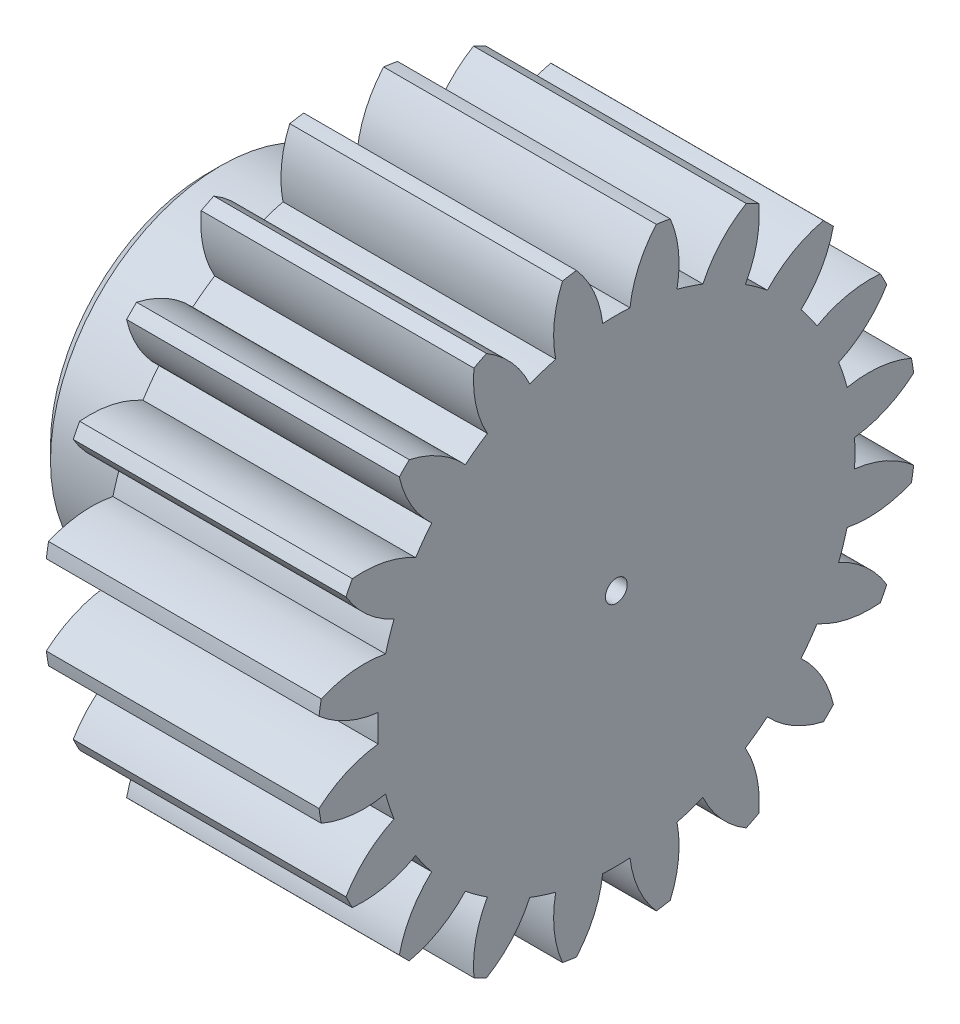
from build123d import *

# Parameters (mm, degrees)
BASPROSKE_W         = 10
BASPROSKE_H         = 11
TOOTHCUT_DEPTH      = 19.493242009
TEETHCUTS_COUNT     = 20
TEETHCUTS_ANGLE     = 342
BORSKE_R            = 0.4
BORE_DEPTH          = 50.0000508
SKETCH1_R           = 6.25
BOSS_EXTRUDE1_DEPTH = 5
FILLET1_R           = 0.5
CHAMFER1_SIZE       = 0.5
SKETCH4_R           = 2.5
CUT_EXTRUDE1_DEPTH  = 2.5


with BuildPart() as part:
    # BasProSke → Base-Revolve (revolve)
    with BuildSketch(Plane(origin=(0, 0, 0), x_dir=(1, 0, 0), z_dir=(0, 1, 0)), mode=Mode.PRIVATE) as base_revolve_sk:
        with Locations((5, 5.5)):
            Rectangle(BASPROSKE_W, BASPROSKE_H)
    revolve(base_revolve_sk.sketch.rotate(Axis((-10, 0, 0), (1, 0, 0)), 180), axis=Axis((-10, 0, 0), (1, 0, 0)))

    # TooCutSke → ToothCut (cut, through all)
    with BuildSketch(Plane(origin=(0, 0, 0), x_dir=(0, 0, -1), z_dir=(1, 0, 0))):
        with BuildLine():
            ThreePointArc((0.499924007, 8.734705318), (0, 8.749), (-0.499924007, 8.734705318))
            ThreePointArc((-0.499924007, 8.734705318), (-0.824302243, 9.905497836), (-1.485192705, 10.924909509))
            ThreePointArc((-1.485192705, 10.924909509), (0, 11.0254), (1.485192705, 10.924909509))
            ThreePointArc((1.485192705, 10.924909509), (0.824302243, 9.905497836), (0.499924007, 8.734705318))
        make_face()
    toothcut = extrude(amount=TOOTHCUT_DEPTH, mode=Mode.SUBTRACT)

    # TeethCuts: ToothCut ×20 about axis
    teethcuts_axis = Axis((-10, 0, 0), (1, 0, 0))
    for i in range(1, TEETHCUTS_COUNT):
        add(toothcut.rotate(teethcuts_axis, i * TEETHCUTS_ANGLE / (TEETHCUTS_COUNT - 1)), mode=Mode.SUBTRACT)

    # BorSke → Bore (cut, symmetric)
    with BuildSketch(Plane(origin=(0, 0, 0), x_dir=(0, 0, -1), z_dir=(1, 0, 0))):
        with Locations(Location((0, 0, 0), (0, 0, 180))):
            Circle(BORSKE_R)
    extrude(amount=BORE_DEPTH, both=True, mode=Mode.SUBTRACT)

    # Sketch1 → Boss-Extrude1 (add)
    with BuildSketch(Plane.ZY):
        with Locations(Location((0, 0, 0), (0, 0, 180))):
            Circle(SKETCH1_R)
    extrude(amount=BOSS_EXTRUDE1_DEPTH)

    # Fillet1
    fillet1_edges = [part.edges().sort_by_distance(p)[0] for p in [
        (0, 0, 6.25),
    ]]
    fillet(fillet1_edges, radius=FILLET1_R)

    # Chamfer1
    chamfer1_edges = [part.edges().sort_by_distance(p)[0] for p in [
        (-5, 0, 6.25),
    ]]
    chamfer(chamfer1_edges, length=CHAMFER1_SIZE)

    # Sketch4 → Cut-Extrude1 (cut)
    with BuildSketch(Plane.ZY.offset(5)):
        Circle(SKETCH4_R)
    extrude(amount=-CUT_EXTRUDE1_DEPTH, mode=Mode.SUBTRACT)


solid = part.part
